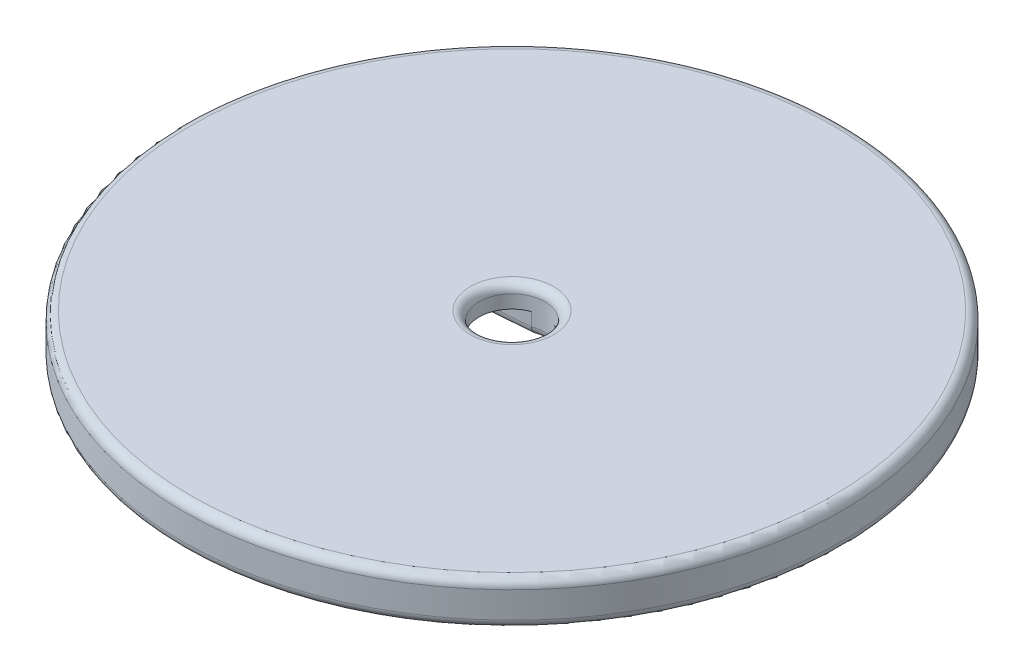
from build123d import *

# Parameters (mm, degrees)
SKETCH1_R           = 37.5
SKETCH1_R_2         = 3.75
BOSS_EXTRUDE1_DEPTH = 5
CUT_EXTRUDE1_DEPTH  = 2.5
FILLET1_R           = 1


with BuildPart() as part:
    # Sketch1 → Boss-Extrude1 (new body)
    with BuildSketch(Plane(origin=(0, 0, 0), x_dir=(1, 0, 0), z_dir=(0, 1, 0))):
        Circle(SKETCH1_R)
        Circle(SKETCH1_R_2, mode=Mode.SUBTRACT)
    extrude(amount=BOSS_EXTRUDE1_DEPTH)

    # Sketch2 → Cut-Extrude1 (cut)
    with BuildSketch(Plane.XZ):
        with BuildLine():
            Line((-14, 2.5), (-1.226116774, 3.543887365))
            ThreePointArc((-1.226116774, 3.543887365), (0, 3.75), (1.226116774, 3.543887365))
            Line((1.226116774, 3.543887365), (14, 2.5))
            ThreePointArc((14, 2.5), (16.5, 0), (14, -2.5))
            Line((14, -2.5), (1.307857892, -3.514542322))
            ThreePointArc((1.307857892, -3.514542322), (0, -3.75), (-1.307857892, -3.514542322))
            Line((-1.307857892, -3.514542322), (-14, -2.5))
            ThreePointArc((-14, -2.5), (-16.5, 0), (-14, 2.5))
        make_face()
    extrude(amount=-CUT_EXTRUDE1_DEPTH, mode=Mode.SUBTRACT)

    # Fillet1
    fillet1_edges = [part.edges().sort_by_distance(p)[0] for p in [
        (0, 0, 3.75),
        (7.653928946, 0, -3.007271161),
        (16.5, 0, 0),
        (-37.5, 0, 0),
        (7.613058387, 0, 3.021943683),
        (-7.613058387, 0, 3.021943683),
        (-16.5, 0, 0),
        (-7.653928946, 0, -3.007271161),
        (-37.5, 5, 0),
        (-3.75, 5, 0),
        (0, 0, -3.75),
    ]]
    fillet(fillet1_edges, radius=FILLET1_R)


solid = part.part
